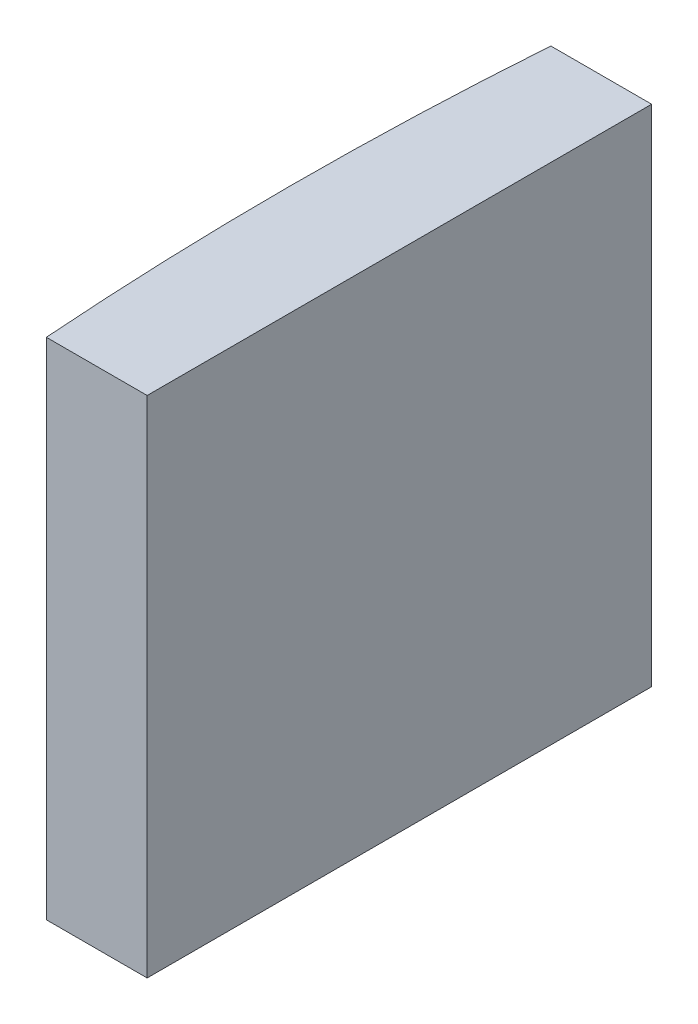
from build123d import *

# Parameters (mm, degrees)
EXTRUDE_1_DEPTH = 10


with BuildPart() as part:
    # 草图1 → 凸台-拉伸1 (new body)
    with BuildSketch(Plane(origin=(0, 0, 0), x_dir=(1, 0, 0), z_dir=(0, 1, 0))):
        with BuildLine():
            Line((-64.242816045, 5), (-62.244795665, 5))
            Line((-62.244795665, 5), (-62.244795665, -5))
            Line((-62.244795665, -5), (-64.242816045, -5))
            ThreePointArc((-64.242816045, -5), (-64.424795665, 0), (-64.242816045, 5))
        make_face()
    extrude(amount=EXTRUDE_1_DEPTH)


solid = part.part
